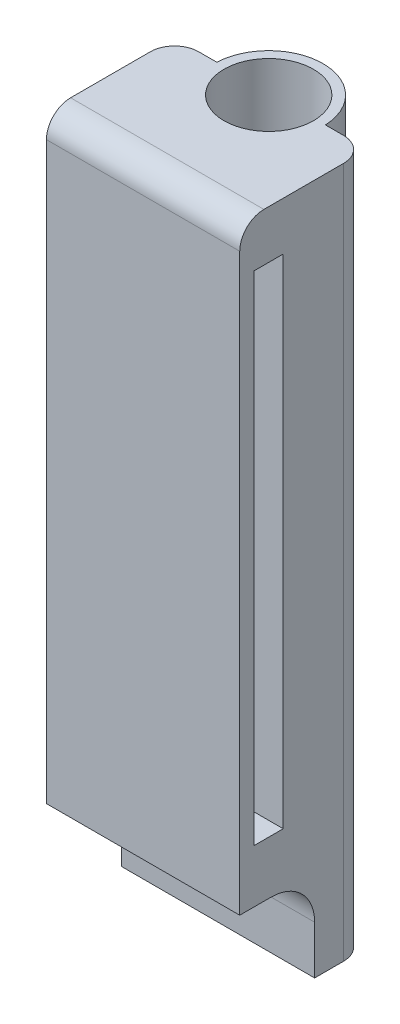
from build123d import *

# Parameters (mm, degrees)
SKETCH1_R           = 9.25
BOSS_EXTRUDE1_DEPTH = 143
FILLET2_R           = 5
SKETCH2_W           = 6
SKETCH2_H           = 103
CUT_EXTRUDE1_DEPTH  = 37
FILLET3_R           = 5
CUT_EXTRUDE2_DEPTH  = 53


with BuildPart() as part:
    # Sketch1 → Boss-Extrude1 (new body)
    with BuildSketch(Plane(origin=(0, 0, 0), x_dir=(1, 0, 0), z_dir=(0, 1, 0))):
        with BuildLine():
            Line((0, -26), (-20, -26))
            Line((-20, -26), (-20, -4.5))
            Line((-20, -4.5), (-20, -2.5))
            Line((-20, -2.5), (-20, 0.5))
            Line((-20, 0.5), (-17, 0.5))
            Line((-17, 0.5), (-11.238883396, 0.5))
            ThreePointArc((-11.238883396, 0.5), (0, 11.25), (11.238883396, 0.5))
            Line((11.238883396, 0.5), (17, 0.5))
            Line((17, 0.5), (20, 0.5))
            Line((20, 0.5), (20, -2.5))
            Line((20, -2.5), (20, -4.5))
            Line((20, -4.5), (20, -26))
            Line((20, -26), (0, -26))
        make_face()
        Circle(SKETCH1_R, mode=Mode.SUBTRACT)
    extrude(amount=BOSS_EXTRUDE1_DEPTH)

    # Fillet2
    fillet2_edges = [part.edges().sort_by_distance(p)[0] for p in [
        (-20, 71.5, -0.5),
        (20, 71.5, -0.5),
    ]]
    fillet(fillet2_edges, radius=FILLET2_R)

    # Sketch2 → Cut-Extrude1 (cut)
    with BuildSketch(Plane(origin=(20, 0, 0), x_dir=(0, 0, -1), z_dir=(1, 0, 0))):
        with Locations((-20, 81.5)):
            Rectangle(SKETCH2_W, SKETCH2_H)
    extrude(amount=-CUT_EXTRUDE1_DEPTH, mode=Mode.SUBTRACT)

    # Fillet3
    fillet3_edges = [part.edges().sort_by_distance(p)[0] for p in [
        (0, 0, 26),
        (0, 143, 26),
    ]]
    fillet(fillet3_edges, radius=FILLET3_R)

    # Sketch3 → Cut-Extrude2 (cut)
    with BuildSketch(Plane(origin=(20, 0, 0), x_dir=(0, 0, -1), z_dir=(1, 0, 0))):
        with BuildLine():
            Line((-10.5, 0), (-10.5, 10))
            ThreePointArc((-10.5, 10), (-13.136038969, 16.363961031), (-19.5, 19))
            Line((-19.5, 19), (-26, 19))
            Line((-26, 19), (-26, 5))
            ThreePointArc((-26, 5), (-24.535533906, 1.464466094), (-21, 0))
            Line((-21, 0), (-10.5, 0))
        make_face()
    extrude(amount=-CUT_EXTRUDE2_DEPTH, mode=Mode.SUBTRACT)


solid = part.part
